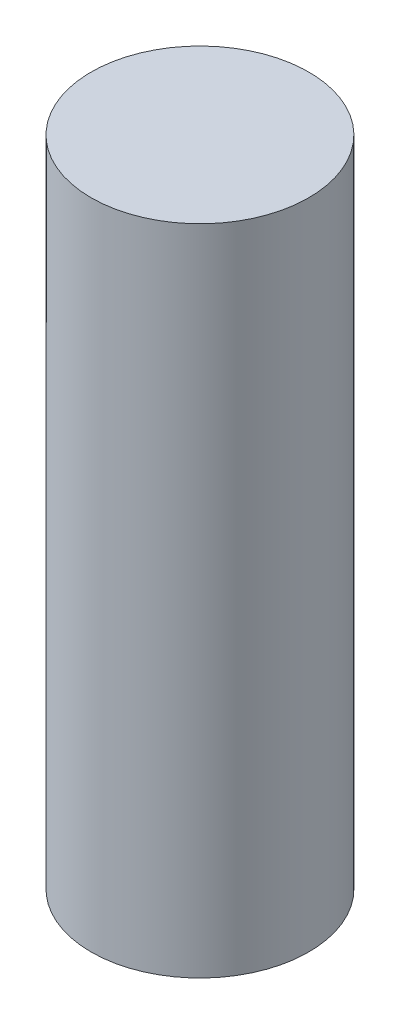
from build123d import *

# Parameters (mm, degrees)
SKETCH_1_R      = 2.5
EXTRUDE_1_DEPTH = 15


with BuildPart() as part:
    # 草图1 → 凸台-拉伸1 (new body)
    with BuildSketch(Plane(origin=(0, 0, 0), x_dir=(1, 0, 0), z_dir=(0, 1, 0))):
        Circle(SKETCH_1_R)
    extrude(amount=EXTRUDE_1_DEPTH)


solid = part.part
